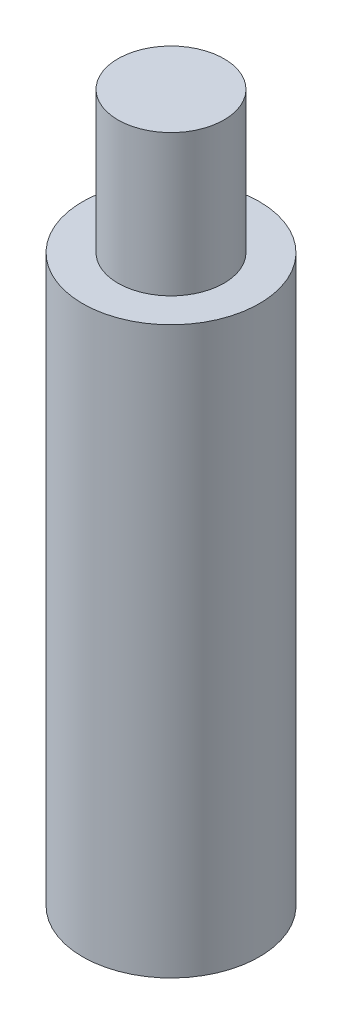
from build123d import *

# Parameters (mm, degrees)
SKETCH_1_R      = 2.5
SKETCH_1_R_2    = 1.5
EXTRUDE_1_DEPTH = 16
SKETCH_2_R      = 1.5
EXTRUDE_2_DEPTH = 4


with BuildPart() as part:
    # 草图1 → 凸台-拉伸1 (new body)
    with BuildSketch(Plane(origin=(0, 0, 0), x_dir=(1, 0, 0), z_dir=(0, 1, 0))):
        Circle(SKETCH_1_R)
        Circle(SKETCH_1_R_2, mode=Mode.SUBTRACT)
    extrude(amount=EXTRUDE_1_DEPTH)


with BuildPart() as body_2:
    # 草图2 → 凸台-拉伸2 (new body)
    with BuildSketch(Plane(origin=(0, 16, 0), x_dir=(1, 0, 0), z_dir=(0, 1, 0))):
        Circle(SKETCH_2_R)
    extrude(amount=EXTRUDE_2_DEPTH)


solid = Compound([part.part, body_2.part])
